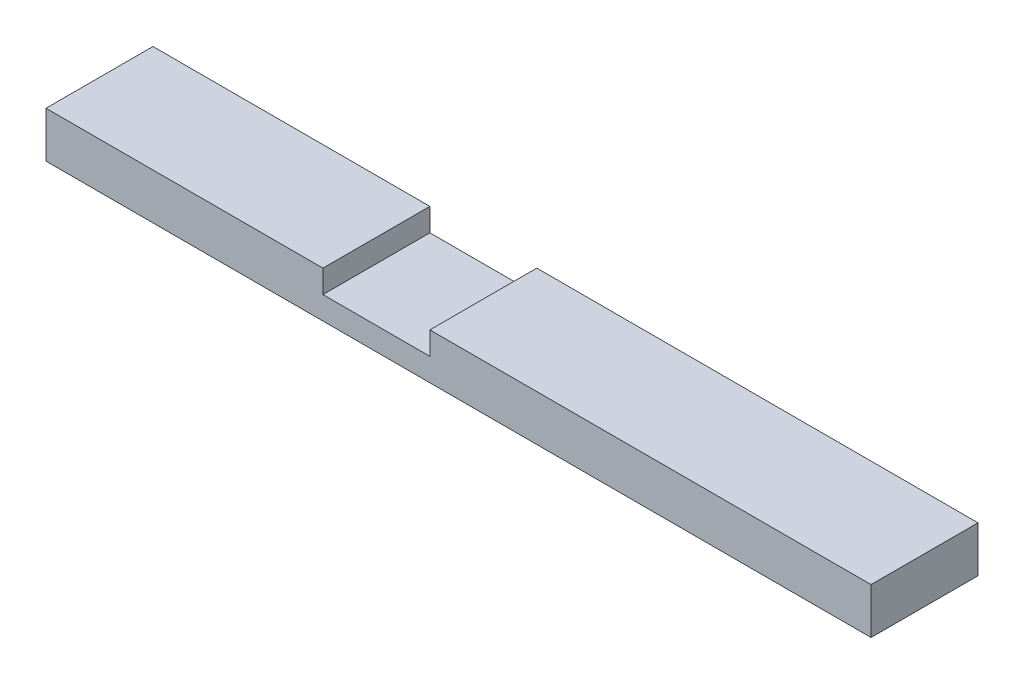
from build123d import *

# Parameters (mm, degrees)
SKETCH1_W           = 685.8
SKETCH1_H           = 88.9
BOSS_EXTRUDE1_DEPTH = 38.1
SKETCH2_W           = 88.9
SKETCH2_H           = 88.9
CUT_EXTRUDE1_DEPTH  = 19.05


with BuildPart() as part:
    # Sketch1 → Boss-Extrude1 (new body)
    with BuildSketch(Plane(origin=(0, 0, 0), x_dir=(1, 0, 0), z_dir=(0, 1, 0))):
        with Locations((342.9, 44.45)):
            Rectangle(SKETCH1_W, SKETCH1_H)
    extrude(amount=BOSS_EXTRUDE1_DEPTH)

    # Sketch2 → Cut-Extrude1 (cut)
    with BuildSketch(Plane(origin=(0, 38.1, 0), x_dir=(1, 0, 0), z_dir=(0, 1, 0))):
        with Locations((274.6375, 44.45)):
            Rectangle(SKETCH2_W, SKETCH2_H)
    extrude(amount=-CUT_EXTRUDE1_DEPTH, mode=Mode.SUBTRACT)


solid = part.part
